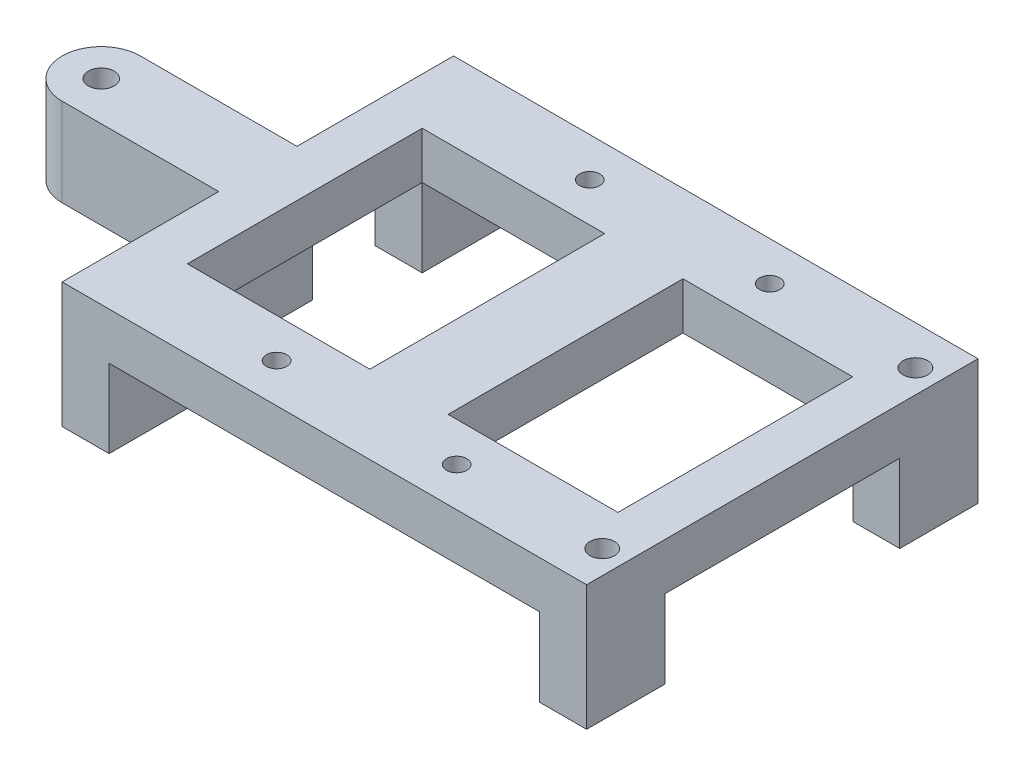
from build123d import *

# Parameters (mm, degrees)
SKETCH1_W               = 85.09
SKETCH1_H               = 40.64
SKETCH1_W_2             = 69.85
SKETCH1_H_2             = 25.4
BOSS_EXTRUDE1_DEPTH     = 12.7
SKETCH2_W               = 7.62
SKETCH2_H               = 7.62
SKETCH2_W_2             = 12.7
BOSS_EXTRUDE2_DEPTH     = 38.1
SKETCH4_W               = 85.09
SKETCH4_H               = 40.64
SKETCH4_W_2             = 69.85
SKETCH4_H_2             = 25.4
BOSS_EXTRUDE3_DEPTH     = 12.7
SKETCH6_W               = 12.7
SKETCH6_H               = 40.64
BOSS_EXTRUDE4_DEPTH     = 2.54
SKETCH7_W               = 12.7
SKETCH7_H               = 5.08
BOSS_EXTRUDE5_DEPTH     = 25.4
SKETCH8_W               = 6.35
SKETCH8_H               = 5.08
REVOLVE2_ANGLE          = 180
SKETCH10_R              = 2.0955
CUT_EXTRUDE4_DEPTH      = 32.4325
M4X0_7_TAPPED_HOLE1_D   = 3.3
SKETCH17_R              = 2.0955
BOSS_EXTRUDE6_DEPTH     = 9.2075
SKETCH18_R              = 2.0955
BOSS_EXTRUDE7_DEPTH     = 6.35
SKETCH24_W              = 63.5
SKETCH24_H              = 20.32
CUT_EXTRUDE9_DEPTH      = 32.75
CUT_EXTRUDE9_DEPTH_BACK = 86.09
CUT_EXTRUDE10_REACH     = 22.32
SKETCH25_R              = 2


with BuildPart() as part:
    # Sketch1 → Boss-Extrude1 (new body)
    with BuildSketch(Plane.XY):
        Rectangle(SKETCH1_W, SKETCH1_H)
        Rectangle(SKETCH1_W_2, SKETCH1_H_2, mode=Mode.SUBTRACT)
    extrude(amount=-BOSS_EXTRUDE1_DEPTH)

    # Sketch2 → Boss-Extrude2 (add)
    with BuildSketch(Plane(origin=(0, 0, -12.7), x_dir=(-1, 0, 0), z_dir=(0, 0, -1))):
        with Locations((-38.735, 16.51)):
            Rectangle(SKETCH2_W, SKETCH2_H)
        with Locations((-1.026508909, 16.51)):
            Rectangle(SKETCH2_W_2, SKETCH2_H)
        with Locations((38.735, 16.51)):
            Rectangle(SKETCH2_W, SKETCH2_H)
        with Locations((38.735, -16.51)):
            Rectangle(SKETCH2_W, SKETCH2_H)
        with Locations((-1.026508909, -16.51)):
            Rectangle(SKETCH2_W_2, SKETCH2_H)
        with Locations((-38.735, -16.51)):
            Rectangle(SKETCH2_W, SKETCH2_H)
    extrude(amount=BOSS_EXTRUDE2_DEPTH)

    # Sketch4 → Boss-Extrude3 (add)
    with BuildSketch(Plane(origin=(0, 0, -50.8), x_dir=(-1, 0, 0), z_dir=(0, 0, -1))):
        Rectangle(SKETCH4_W, SKETCH4_H)
        Rectangle(SKETCH4_W_2, SKETCH4_H_2, mode=Mode.SUBTRACT)
    extrude(amount=BOSS_EXTRUDE3_DEPTH)

    # Sketch6 → Boss-Extrude4 (add)
    with BuildSketch(Plane.ZY.offset(42.545)):
        with Locations((-31.75, 0)):
            Rectangle(SKETCH6_W, SKETCH6_H)
    extrude(amount=-BOSS_EXTRUDE4_DEPTH)

    # Sketch7 → Boss-Extrude5 (add)
    with BuildSketch(Plane.ZY.offset(42.545)):
        with Locations((-31.75, 8.5725)):
            Rectangle(SKETCH7_W, SKETCH7_H)
        with Locations((-31.75, -8.5725)):
            Rectangle(SKETCH7_W, SKETCH7_H)
    extrude(amount=BOSS_EXTRUDE5_DEPTH)

    # Sketch8 → Revolve2 (revolve)
    with BuildSketch(Plane.ZY.offset(67.945)):
        with Locations((-28.575, 8.5725)):
            Rectangle(SKETCH8_W, SKETCH8_H)
        with Locations((-28.575, -8.5725)):
            Rectangle(SKETCH8_W, SKETCH8_H)
    revolve(axis=Axis((-67.945, 11.1125, -31.75), (0, -1, 0)), revolution_arc=REVOLVE2_ANGLE)

    # Sketch10 → Cut-Extrude4 (cut, through all)
    with BuildSketch(Plane(origin=(0, 11.1125, 0), x_dir=(1, 0, 0), z_dir=(0, 1, 0))):
        with Locations((-67.945, 31.75)):
            Circle(SKETCH10_R)
    extrude(amount=-CUT_EXTRUDE4_DEPTH, mode=Mode.SUBTRACT)

    # M4x0.7 Tapped Hole1 (through all)
    with Locations(Plane(origin=(0, 20.32, 0), x_dir=(1, 0, 0), z_dir=(0, 1, 0))):
        with Locations((-14.101699785, 57.15), (15.108300215, 57.15), (15.108300215, 6.35), (-14.101699785, 6.35)):
            Hole(M4X0_7_TAPPED_HOLE1_D / 2)

    # Sketch17 → Boss-Extrude6 (add)
    with BuildSketch(Plane(origin=(0, 11.1125, 0), x_dir=(1, 0, 0), z_dir=(0, 1, 0))):
        with BuildLine():
            Line((-67.945, 25.4), (-42.545, 25.4))
            Line((-42.545, 25.4), (-42.545, 38.1))
            Line((-42.545, 38.1), (-67.945, 38.1))
            ThreePointArc((-67.945, 38.1), (-74.295, 31.75), (-67.945, 25.4))
        make_face()
        with Locations((-67.945, 31.75)):
            Circle(SKETCH17_R, mode=Mode.SUBTRACT)
    extrude(amount=BOSS_EXTRUDE6_DEPTH)

    # Sketch18 → Boss-Extrude7 (add)
    with BuildSketch(Plane.XZ.offset(11.1125)):
        with BuildLine():
            Line((-42.545, -38.1), (-42.545, -25.4))
            Line((-42.545, -25.4), (-67.945, -25.4))
            ThreePointArc((-67.945, -25.4), (-74.295, -31.75), (-67.945, -38.1))
            Line((-67.945, -38.1), (-42.545, -38.1))
        make_face()
        with Locations((-67.945, -31.75)):
            Circle(SKETCH18_R, mode=Mode.SUBTRACT)
    extrude(amount=BOSS_EXTRUDE7_DEPTH)

    # Sketch24 → Cut-Extrude9 (cut, two sides)
    with BuildSketch(Plane.ZY.offset(42.545)) as cut_extrude9_sk:
        with Locations((-31.75, -10.16)):
            Rectangle(SKETCH24_W, SKETCH24_H)
    extrude(amount=CUT_EXTRUDE9_DEPTH, mode=Mode.SUBTRACT)
    extrude(cut_extrude9_sk.sketch, amount=-CUT_EXTRUDE9_DEPTH_BACK, mode=Mode.SUBTRACT)

    # Sketch25 → Cut-Extrude10 (cut, up to next)
    with BuildSketch(Plane(origin=(0, 20.32, 0), x_dir=(1, 0, 0), z_dir=(0, 1, 0)), mode=Mode.PRIVATE) as cut_extrude10_sk1:
        with Locations((38.735, 57.15)):
            Circle(SKETCH25_R)
    cut_extrude10_tool1 = extrude(cut_extrude10_sk1.sketch, amount=-CUT_EXTRUDE10_REACH, mode=Mode.PRIVATE) & part.part
    add(cut_extrude10_tool1.solids().sort_by_distance((38.735, 20.32, -57.15))[0], mode=Mode.SUBTRACT)
    # Sketch25 → Cut-Extrude10 (cut, up to next)
    with BuildSketch(Plane(origin=(0, 20.32, 0), x_dir=(1, 0, 0), z_dir=(0, 1, 0)), mode=Mode.PRIVATE) as cut_extrude10_sk2:
        with Locations((38.735, 6.35)):
            Circle(SKETCH25_R)
    cut_extrude10_tool2 = extrude(cut_extrude10_sk2.sketch, amount=-CUT_EXTRUDE10_REACH, mode=Mode.PRIVATE) & part.part
    add(cut_extrude10_tool2.solids().sort_by_distance((38.735, 20.32, -6.35))[0], mode=Mode.SUBTRACT)


solid = part.part
